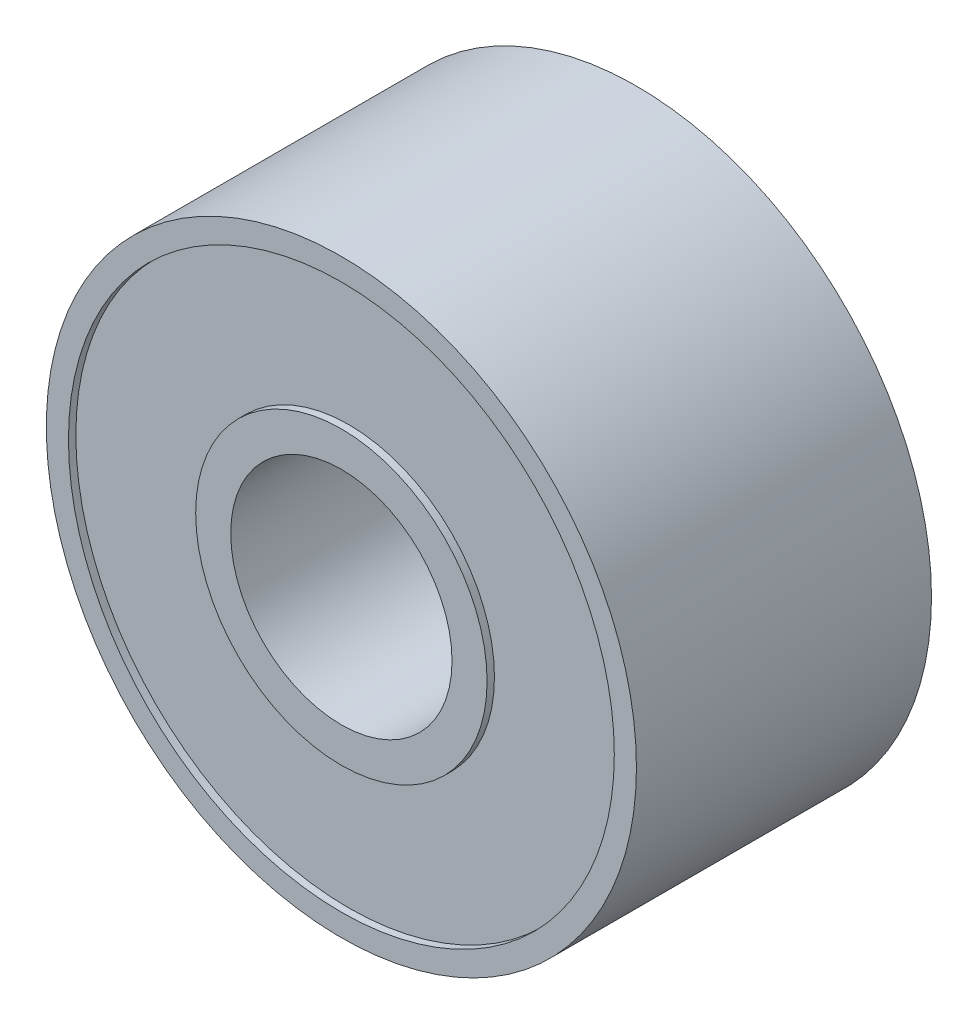
from build123d import *

# Parameters (mm, degrees)
SKETCH1_R           = 4
SKETCH1_R_2         = 1.5
BOSS_EXTRUDE1_DEPTH = 4
SKETCH2_R           = 3.7
SKETCH2_R_2         = 1.975178003
CUT_EXTRUDE1_DEPTH  = 0.1
SKETCH3_R           = 3.7
SKETCH3_R_2         = 1.975178003
CUT_EXTRUDE2_DEPTH  = 0.1


with BuildPart() as part:
    # Sketch1 → Boss-Extrude1 (new body)
    with BuildSketch(Plane.XY):
        Circle(SKETCH1_R)
        Circle(SKETCH1_R_2, mode=Mode.SUBTRACT)
    extrude(amount=BOSS_EXTRUDE1_DEPTH)

    # Sketch2 → Cut-Extrude1 (cut)
    with BuildSketch(Plane.XY.offset(4)):
        Circle(SKETCH2_R)
        Circle(SKETCH2_R_2, mode=Mode.SUBTRACT)
    extrude(amount=-CUT_EXTRUDE1_DEPTH, mode=Mode.SUBTRACT)

    # Sketch3 → Cut-Extrude2 (cut)
    with BuildSketch(Plane(origin=(0, 0, 0), x_dir=(-1, 0, 0), z_dir=(0, 0, -1))):
        Circle(SKETCH3_R)
        Circle(SKETCH3_R_2, mode=Mode.SUBTRACT)
    extrude(amount=-CUT_EXTRUDE2_DEPTH, mode=Mode.SUBTRACT)


solid = part.part
